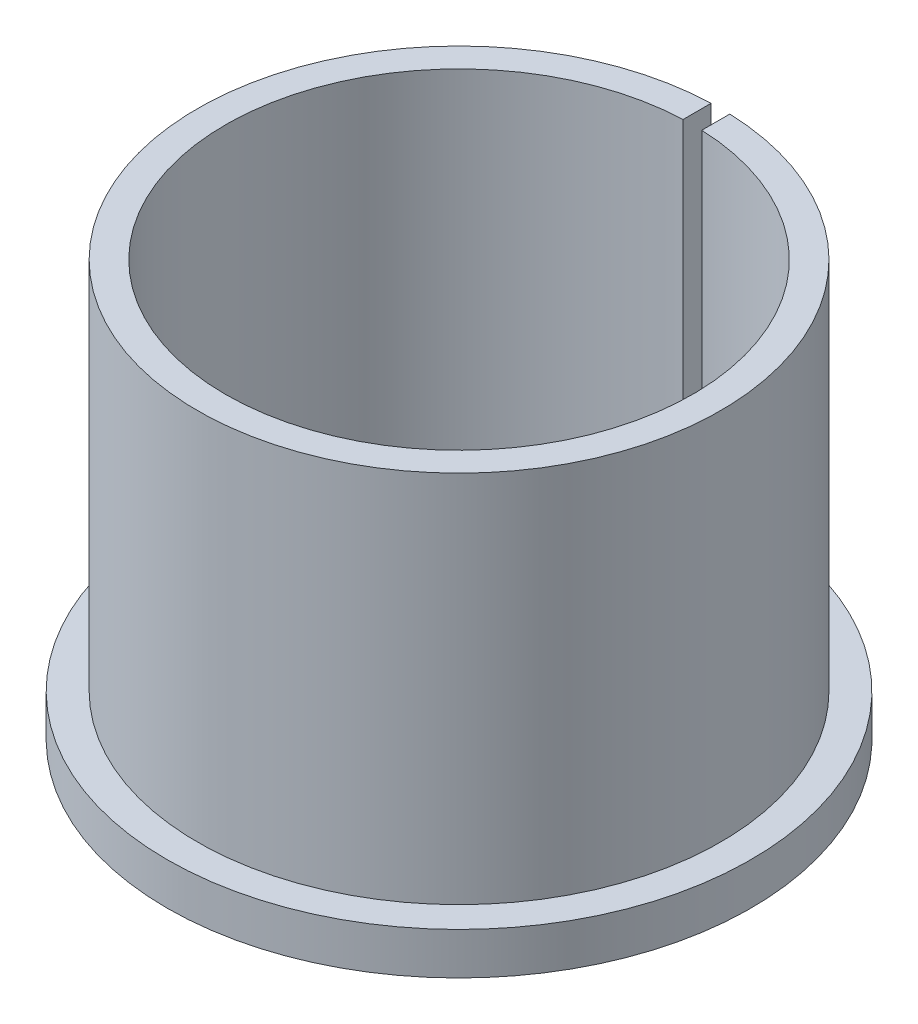
from build123d import *

# Parameters (mm, degrees)
ESQUISSE2_W             = 2
ESQUISSE2_H             = 44.5
ENL_V_MAT_EXTRU_1_DEPTH = 32.25


with BuildPart() as part:
    # Esquisse1 → Révolution1 (revolve)
    with BuildSketch(Plane(origin=(0, 0, 0), x_dir=(0, 0, -1), z_dir=(1, 0, 0))):
        Polygon((25, 44.5), (25, 0), (31.25, 0), (31.25, 4.5), (28, 4.5), (28, 44.5), align=None)
    revolve(axis=Axis((0, 0, 0), (0, 1, 0)))

    # Esquisse2 → Enlèv. mat.-Extru.1 (cut, through all)
    with BuildSketch(Plane.XY):
        with Locations((0, 22.25)):
            Rectangle(ESQUISSE2_W, ESQUISSE2_H)
    extrude(amount=-ENL_V_MAT_EXTRU_1_DEPTH, mode=Mode.SUBTRACT)


solid = part.part
